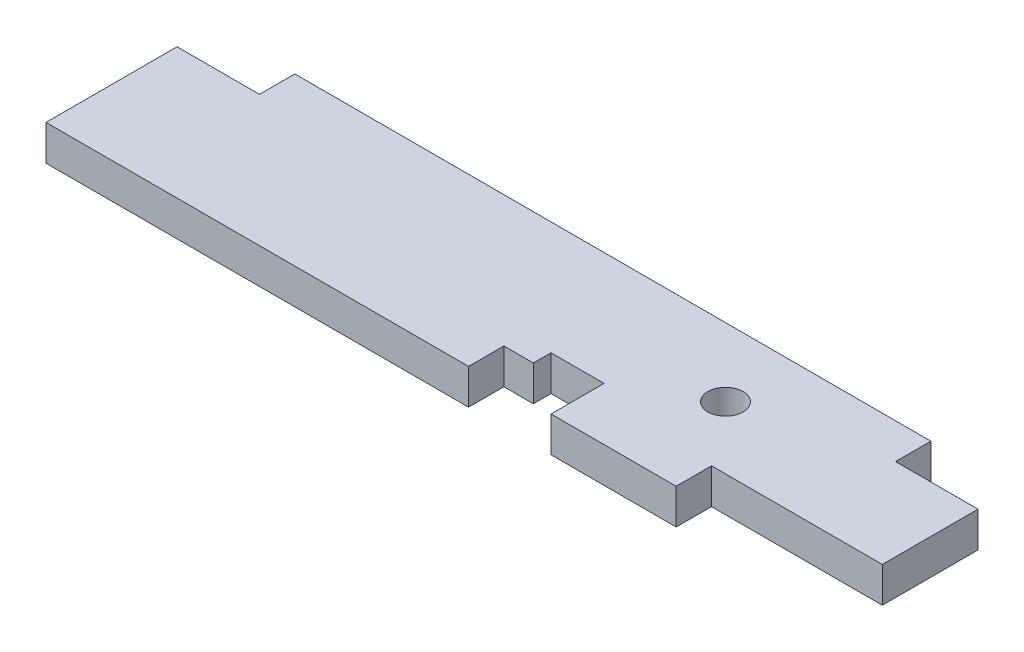
from build123d import *

# Parameters (mm, degrees)
SKETCH1_R           = 19.05
BOSS_EXTRUDE1_DEPTH = 38.1
CUT_EXTRUDE5_DEPTH  = 39.1
SKETCH8_W           = 184.15
SKETCH8_H           = 38.1127
CUT_EXTRUDE6_DEPTH  = 39.1
SKETCH9_W           = 88.9
SKETCH9_H           = 38.1
CUT_EXTRUDE7_DEPTH  = 39.1


with BuildPart() as part:
    # Sketch1 → Boss-Extrude1 (new body)
    with BuildSketch(Plane(origin=(0, 0, 0), x_dir=(1, 0, 0), z_dir=(0, 1, 0))):
        Polygon((0, 0), (774.7, 0), (774.7, -38.1), (863.6, -38.1), (863.6, -179.3875), (0, -179.3875), align=None)
        with Locations((627.126, -73.914)):
            Circle(SKETCH1_R, mode=Mode.SUBTRACT)
    extrude(amount=BOSS_EXTRUDE1_DEPTH)

    # Sketch7 → Cut-Extrude5 (cut, through all)
    with BuildSketch(Plane(origin=(0, 38.1, 0), x_dir=(1, 0, 0), z_dir=(0, 1, 0))):
        Polygon((455.6125, -141.2875), (487.3625, -141.2875), (487.3625, -122.2375), (544.5125, -122.2375), (544.5125, -179.3875), (455.6125, -179.3875), align=None)
    extrude(amount=-CUT_EXTRUDE5_DEPTH, mode=Mode.SUBTRACT)

    # Sketch8 → Cut-Extrude6 (cut, through all)
    with BuildSketch(Plane(origin=(0, 38.1, 0), x_dir=(1, 0, 0), z_dir=(0, 1, 0))):
        with Locations((771.525, -160.33115)):
            Rectangle(SKETCH8_W, SKETCH8_H)
    extrude(amount=-CUT_EXTRUDE6_DEPTH, mode=Mode.SUBTRACT)

    # Sketch9 → Cut-Extrude7 (cut, through all)
    with BuildSketch(Plane.XZ):
        with Locations((44.45, 19.05)):
            Rectangle(SKETCH9_W, SKETCH9_H)
    extrude(amount=-CUT_EXTRUDE7_DEPTH, mode=Mode.SUBTRACT)


solid = part.part
